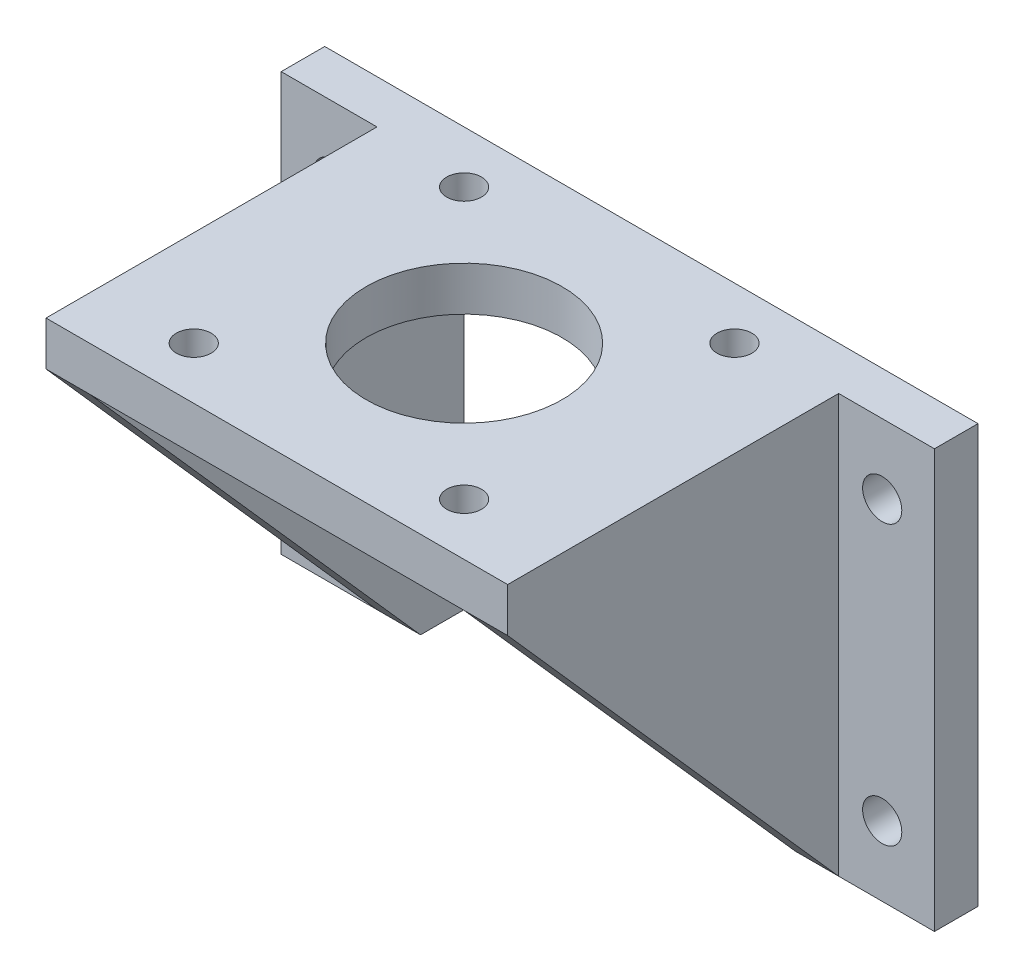
from build123d import *

# Parameters (mm, degrees)
SKETCH1_R           = 2.25
BOSS_EXTRUDE1_DEPTH = 5
SKETCH2_W           = 53
SKETCH2_H           = 5.069282957
BOSS_EXTRUDE2_DEPTH = 38
BOSS_EXTRUDE3_DEPTH = 5
BOSS_EXTRUDE4_DEPTH = 5
SKETCH5_R           = 11.25
SKETCH5_R_2         = 2
CUT_EXTRUDE1_DEPTH  = 49


with BuildPart() as part:
    # Sketch1 → Boss-Extrude1 (new body)
    with BuildSketch(Plane.XY):
        Polygon((0, 0), (0, 43), (43, 43), (43, 0), (59, 0), (59, 48), (-16, 48), (-16, 0), align=None)
        with Locations((-10, 40)):
            Circle(SKETCH1_R, mode=Mode.SUBTRACT)
        with Locations((53, 40)):
            Circle(SKETCH1_R, mode=Mode.SUBTRACT)
        with Locations((53, 8)):
            Circle(SKETCH1_R, mode=Mode.SUBTRACT)
        with Locations((-10, 8)):
            Circle(SKETCH1_R, mode=Mode.SUBTRACT)
    extrude(amount=BOSS_EXTRUDE1_DEPTH)

    # Sketch2 → Boss-Extrude2 (add)
    with BuildSketch(Plane.XY.offset(5)):
        with Locations((21.5, 45.465358522)):
            Rectangle(SKETCH2_W, SKETCH2_H)
    extrude(amount=BOSS_EXTRUDE2_DEPTH)

    # Sketch3 → Boss-Extrude3 (add)
    with BuildSketch(Plane.ZY.offset(5)):
        Polygon((5, 48), (5, 0), (43, 42.930717043), (43, 48), align=None)
    extrude(amount=-BOSS_EXTRUDE3_DEPTH)

    # Sketch4 → Boss-Extrude4 (add)
    with BuildSketch(Plane(origin=(48, 0, 0), x_dir=(0, 0, -1), z_dir=(1, 0, 0))):
        Polygon((-43, 48), (-43, 42.930717043), (-5, 0), (-5, 48), align=None)
    extrude(amount=-BOSS_EXTRUDE4_DEPTH)

    # Sketch5 → Cut-Extrude1 (cut, through all)
    with BuildSketch(Plane(origin=(0, 48, 0), x_dir=(1, 0, 0), z_dir=(0, 1, 0))):
        with Locations((21.5, -21.5)):
            Circle(SKETCH5_R)
        with Locations((5.98, -5.98)):
            Circle(SKETCH5_R_2)
        with Locations((37.02, -5.98)):
            Circle(SKETCH5_R_2)
        with Locations((37.02, -37.02)):
            Circle(SKETCH5_R_2)
        with Locations((5.98, -37.02)):
            Circle(SKETCH5_R_2)
    extrude(amount=-CUT_EXTRUDE1_DEPTH, mode=Mode.SUBTRACT)


solid = part.part
